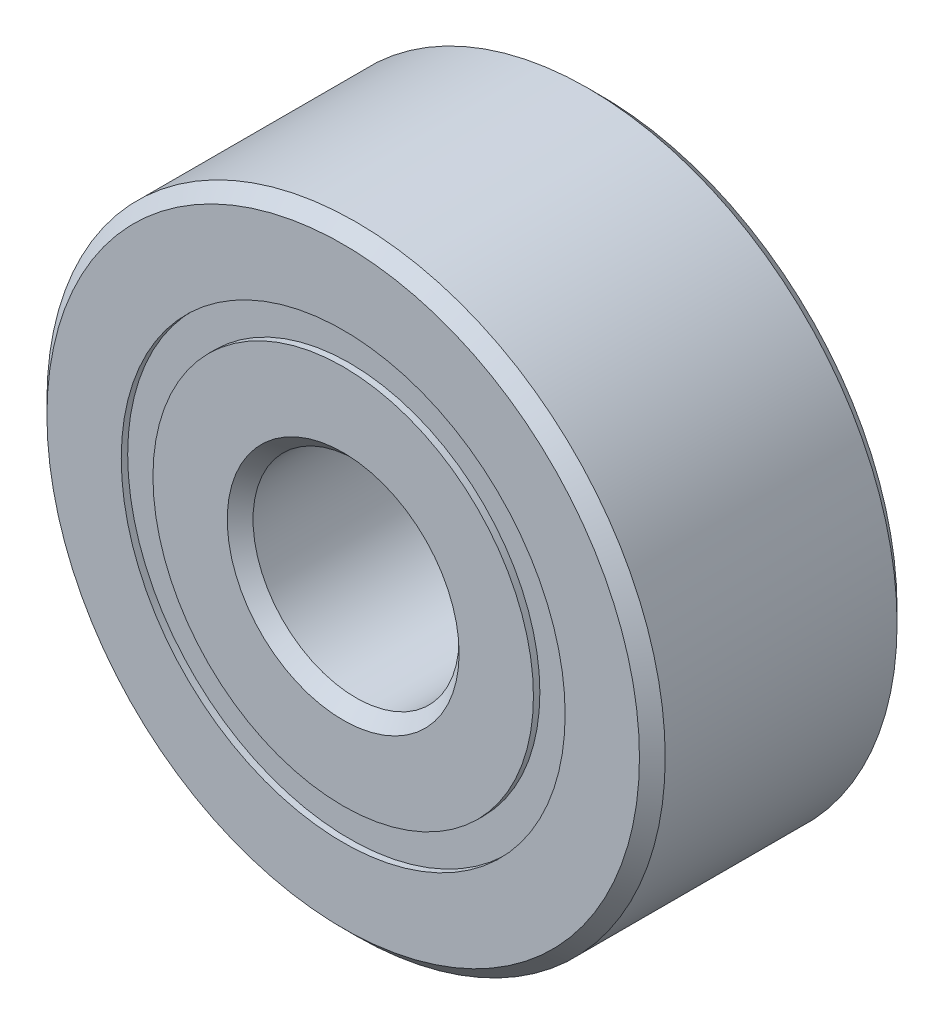
from build123d import *

# Parameters (mm, degrees)
CIRPATTERN1_COUNT = 6
SKETCH5_W         = 0.970019828
SKETCH5_H         = 0.488461538


with BuildPart() as part:
    # Sketch1 → Revolve1 (revolve)
    with BuildSketch(Plane(origin=(0, 0, 0), x_dir=(0, 0, -1), z_dir=(1, 0, 0))):
        with BuildLine():
            Line((1.7859375, 4.7625), (-1.7859375, 4.7625))
            Line((-1.7859375, 4.7625), (-1.984375, 4.5640625))
            Line((-1.984375, 4.5640625), (-1.984375, 3.419230769))
            Line((-1.984375, 3.419230769), (-0.881944444, 3.419230769))
            ThreePointArc((-0.881944444, 3.419230769), (0, 4.090136422), (0.881944444, 3.419230769))
            Line((0.881944444, 3.419230769), (1.984375, 3.419230769))
            Line((1.984375, 3.419230769), (1.984375, 4.5640625))
            Line((1.984375, 4.5640625), (1.7859375, 4.7625))
        make_face()
    revolve(axis=Axis((0, 0, 1.984375), (0, 0, -1)))


with BuildPart() as body_2:
    # Sketch3 → Revolve3 (revolve)
    with BuildSketch(Plane(origin=(0, 0, 0), x_dir=(0, 0, -1), z_dir=(1, 0, 0))):
        with BuildLine():
            Line((-1.984375, 2.930769231), (-0.881944444, 2.930769231))
            ThreePointArc((-0.881944444, 2.930769231), (0, 2.259863578), (0.881944444, 2.930769231))
            Line((0.881944444, 2.930769231), (1.984375, 2.930769231))
            Line((1.984375, 2.930769231), (1.984375, 1.7859375))
            Line((1.984375, 1.7859375), (1.7859375, 1.5875))
            Line((1.7859375, 1.5875), (-1.7859375, 1.5875))
            Line((-1.7859375, 1.5875), (-1.984375, 1.7859375))
            Line((-1.984375, 1.7859375), (-1.984375, 2.930769231))
        make_face()
    revolve(axis=Axis((0, 0, 1.984375), (0, 0, -1)))


with BuildPart() as body_3:
    # Sketch4 → Revolve4 (revolve)
    with BuildSketch(Plane(origin=(0, 0, 0), x_dir=(0, 0, -1), z_dir=(1, 0, 0))):
        with BuildLine():
            Line((-0.915136422, 3.175), (0.915136422, 3.175))
            ThreePointArc((0.915136422, 3.175), (0, 4.090136422), (-0.915136422, 3.175))
        make_face()
    revolve(axis=Axis((0, 3.175, 0.915136422), (0, 0, -1)))


with BuildPart() as cirpattern1_1:
    # CirPattern1: pattern copy
    add(body_3.part.rotate(Axis((0, 0, -1.984375), (0, 0, 1)), 1 * 360 / CIRPATTERN1_COUNT))


with BuildPart() as cirpattern1_2:
    # CirPattern1: pattern copy
    add(body_3.part.rotate(Axis((0, 0, -1.984375), (0, 0, 1)), 2 * 360 / CIRPATTERN1_COUNT))


with BuildPart() as cirpattern1_3:
    # CirPattern1: pattern copy
    add(body_3.part.rotate(Axis((0, 0, -1.984375), (0, 0, 1)), 3 * 360 / CIRPATTERN1_COUNT))


with BuildPart() as cirpattern1_4:
    # CirPattern1: pattern copy
    add(body_3.part.rotate(Axis((0, 0, -1.984375), (0, 0, 1)), 4 * 360 / CIRPATTERN1_COUNT))


with BuildPart() as cirpattern1_5:
    # CirPattern1: pattern copy
    add(body_3.part.rotate(Axis((0, 0, -1.984375), (0, 0, 1)), 5 * 360 / CIRPATTERN1_COUNT))


with BuildPart() as body_9:
    # Sketch5 → Revolve5 (revolve)
    with BuildSketch(Plane(origin=(0, 0, 0), x_dir=(0, 0, -1), z_dir=(1, 0, 0))):
        with Locations((-1.400146336, 3.175)):
            Rectangle(SKETCH5_W, SKETCH5_H)
        with Locations((1.400146336, 3.175)):
            Rectangle(SKETCH5_W, SKETCH5_H)
    revolve(axis=Axis((0, 0, 1.984375), (0, 0, -1)))


solid = Compound([part.part, body_2.part, body_3.part, cirpattern1_1.part, cirpattern1_2.part, cirpattern1_3.part, cirpattern1_4.part, cirpattern1_5.part, body_9.part])
